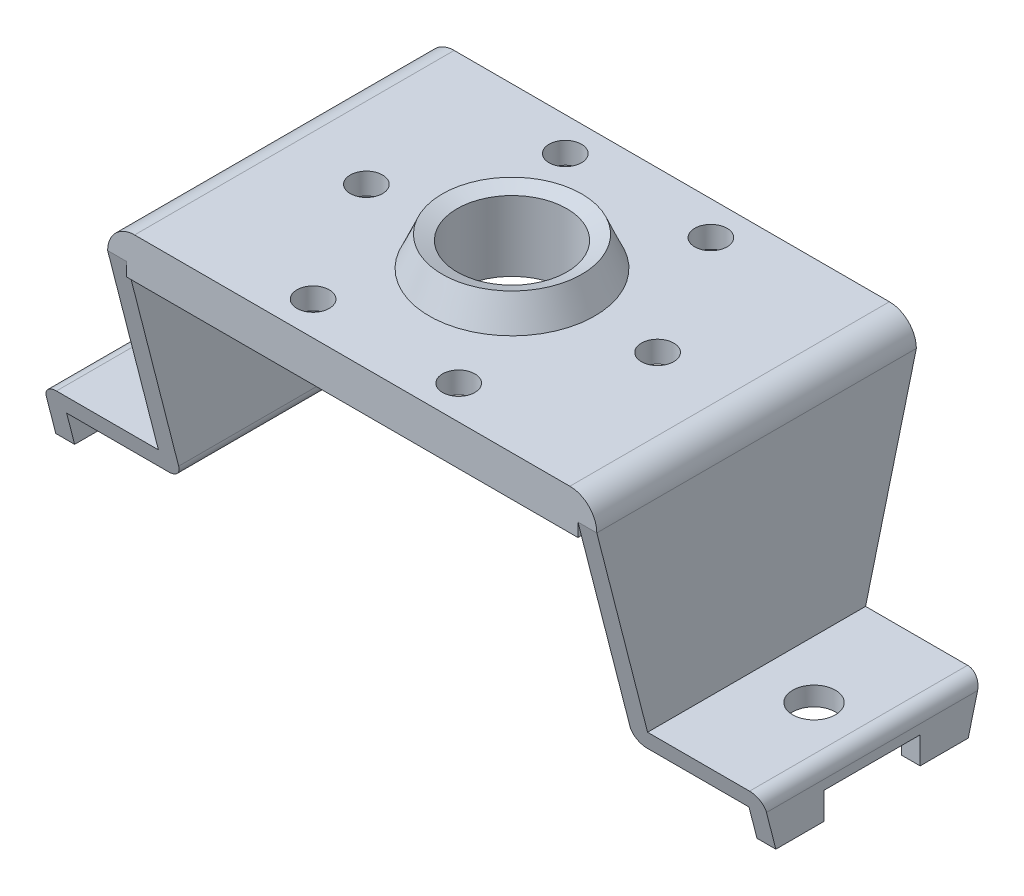
from build123d import *

# Parameters (mm, degrees)
SKETCH1_R                       = 7.7978
SKETCH1_R_2                     = 6.57225
SKETCH1_R_3                     = 5.17525
BOSS_EXTRUDE1_DEPTH             = 2.032
BOSS_EXTRUDE2_REACH             = 17.062
BOSS_EXTRUDE2_DIRECTION_2_REACH = 17.062
SKETCH4_W                       = 3.302
SKETCH4_H                       = 2.032
BOSS_EXTRUDE3_DEPTH             = 30.1244
FILLET1_R                       = 2.54
FILLET2_R                       = 2.54
SKETCH5_W                       = 9.0678
SKETCH5_H                       = 2.54
CUT_EXTRUDE1_DEPTH              = 116.84
SKETCH6_R                       = 2.01295
CUT_EXTRUDE2_DEPTH              = 5.7117
SKETCH7_R                       = 1.524
CUT_EXTRUDE3_DEPTH              = 26.9207
CUT_EXTRUDE4_DEPTH              = 116.84
CUT_EXTRUDE4_DEPTH_BACK         = 116.84
SKETCH9_W                       = 42.5577
SKETCH9_H                       = 30.1244
SKETCH9_W_2                     = 39.0017
SKETCH9_H_2                     = 26.5684
BOSS_EXTRUDE4_DEPTH             = 1.778


with BuildPart() as part:
    # Sketch1 → Boss-Extrude1 (new body)
    with BuildSketch(Plane(origin=(0, 0, 0), x_dir=(1, 0, 0), z_dir=(0, 1, 0))):
        with BuildLine():
            ThreePointArc((-23.05685, 9.9822), (-21.568952448, 13.574302448), (-17.97685, 15.0622))
            Line((-17.97685, 15.0622), (17.97685, 15.0622))
            ThreePointArc((17.97685, 15.0622), (21.568952448, 13.574302448), (23.05685, 9.9822))
            Line((23.05685, 9.9822), (23.05685, -9.9822))
            ThreePointArc((23.05685, -9.9822), (21.568952448, -13.574302448), (17.97685, -15.0622))
            Line((17.97685, -15.0622), (-17.97685, -15.0622))
            ThreePointArc((-17.97685, -15.0622), (-21.568952448, -13.574302448), (-23.05685, -9.9822))
            Line((-23.05685, -9.9822), (-23.05685, 9.9822))
        make_face()
        Circle(SKETCH1_R, mode=Mode.SUBTRACT)
        Circle(SKETCH1_R)
        Circle(SKETCH1_R_2, mode=Mode.SUBTRACT)
        Circle(SKETCH1_R_2)
        Circle(SKETCH1_R_3, mode=Mode.SUBTRACT)
    extrude(amount=-BOSS_EXTRUDE1_DEPTH)

    # Sketch2 → Revolve1 (revolve)
    with BuildSketch(Plane(origin=(0, 0, 0), x_dir=(0, 0, -1), z_dir=(1, 0, 0))):
        Polygon((-5.17525, 2.286), (-6.57225, 2.794), (-7.7978, 0), (-5.17525, 0), align=None)
    revolve1 = revolve(axis=Axis((0, 0, 0), (0, 1, 0)))

    # Boss-Extrude2: up to this face of the body (flat: up to its plane)
    boss_extrude2_end = Plane(part.part.faces().sort_by_distance((0, -1.016, 15.0622))[0])
    # Sketch3 → Boss-Extrude2 (add, up to the picked face)
    with BuildSketch(Plane.XY, mode=Mode.PRIVATE) as boss_extrude2_sk1:
        with BuildLine():
            ThreePointArc((-23.05685, -1.27), (-22.684875612, -0.371974388), (-21.78685, 0))
            Line((-21.78685, 0), (-21.27885, 0))
            Line((-21.27885, 0), (-21.27885, -21.717))
            ThreePointArc((-21.27885, -21.717), (-21.650824388, -22.615025612), (-22.54885, -22.987))
            Line((-22.54885, -22.987), (-23.05685, -22.987))
            Line((-23.05685, -22.987), (-32.16275, -22.987))
            Line((-32.16275, -22.987), (-32.16275, -25.9207))
            Line((-32.16275, -25.9207), (-33.94075, -25.9207))
            Line((-33.94075, -25.9207), (-33.94075, -22.479))
            ThreePointArc((-33.94075, -22.479), (-33.568775612, -21.580974388), (-32.67075, -21.209))
            Line((-32.67075, -21.209), (-32.16275, -21.209))
            Line((-32.16275, -21.209), (-23.05685, -21.209))
            Line((-23.05685, -21.209), (-23.05685, -1.27))
        make_face()
    boss_extrude2_tool1 = split(extrude(boss_extrude2_sk1.sketch, amount=BOSS_EXTRUDE2_REACH, mode=Mode.PRIVATE), bisect_by=boss_extrude2_end, keep=Keep.BOTH, mode=Mode.PRIVATE)
    add(boss_extrude2_tool1.solids().sort_by_distance((-32.41675, -21.49748, 0))[0])
    # Sketch3 → Boss-Extrude2 (add, up to the picked face)
    with BuildSketch(Plane.XY, mode=Mode.PRIVATE) as boss_extrude2_sk2:
        with BuildLine():
            Line((21.27885, 0), (21.27885, -21.717))
            ThreePointArc((21.27885, -21.717), (21.650824388, -22.615025612), (22.54885, -22.987))
            Line((22.54885, -22.987), (23.05685, -22.987))
            Line((23.05685, -22.987), (32.16275, -22.987))
            Line((32.16275, -22.987), (32.16275, -25.9207))
            Line((32.16275, -25.9207), (33.94075, -25.9207))
            Line((33.94075, -25.9207), (33.94075, -22.479))
            ThreePointArc((33.94075, -22.479), (33.568775612, -21.580974388), (32.67075, -21.209))
            Line((32.67075, -21.209), (32.16275, -21.209))
            Line((32.16275, -21.209), (23.05685, -21.209))
            Line((23.05685, -21.209), (23.05685, -1.27))
            ThreePointArc((23.05685, -1.27), (22.684875612, -0.371974388), (21.78685, 0))
            Line((21.78685, 0), (21.27885, 0))
        make_face()
    boss_extrude2_tool2 = split(extrude(boss_extrude2_sk2.sketch, amount=BOSS_EXTRUDE2_REACH, mode=Mode.PRIVATE), bisect_by=boss_extrude2_end, keep=Keep.BOTH, mode=Mode.PRIVATE)
    add(boss_extrude2_tool2.solids().sort_by_distance((32.41675, -21.49748, 0))[0])

    # Boss-Extrude2 direction 2: up to this face of the body (flat: up to its plane)
    boss_extrude2_direction_2_end = Plane(part.part.faces().sort_by_distance((0, -1.016, -15.0622))[0])
    # Sketch3 → Boss-Extrude2 direction 2 (add, up to the picked face)
    with BuildSketch(Plane.XY, mode=Mode.PRIVATE) as boss_extrude2_direction_2_sk1:
        with BuildLine():
            ThreePointArc((-23.05685, -1.27), (-22.684875612, -0.371974388), (-21.78685, 0))
            Line((-21.78685, 0), (-21.27885, 0))
            Line((-21.27885, 0), (-21.27885, -21.717))
            ThreePointArc((-21.27885, -21.717), (-21.650824388, -22.615025612), (-22.54885, -22.987))
            Line((-22.54885, -22.987), (-23.05685, -22.987))
            Line((-23.05685, -22.987), (-32.16275, -22.987))
            Line((-32.16275, -22.987), (-32.16275, -25.9207))
            Line((-32.16275, -25.9207), (-33.94075, -25.9207))
            Line((-33.94075, -25.9207), (-33.94075, -22.479))
            ThreePointArc((-33.94075, -22.479), (-33.568775612, -21.580974388), (-32.67075, -21.209))
            Line((-32.67075, -21.209), (-32.16275, -21.209))
            Line((-32.16275, -21.209), (-23.05685, -21.209))
            Line((-23.05685, -21.209), (-23.05685, -1.27))
        make_face()
    boss_extrude2_direction_2_tool1 = split(extrude(boss_extrude2_direction_2_sk1.sketch, amount=-BOSS_EXTRUDE2_DIRECTION_2_REACH, mode=Mode.PRIVATE), bisect_by=boss_extrude2_direction_2_end, keep=Keep.BOTH, mode=Mode.PRIVATE)
    add(boss_extrude2_direction_2_tool1.solids().sort_by_distance((-32.41675, -21.49748, 0))[0])
    # Sketch3 → Boss-Extrude2 direction 2 (add, up to the picked face)
    with BuildSketch(Plane.XY, mode=Mode.PRIVATE) as boss_extrude2_direction_2_sk2:
        with BuildLine():
            Line((21.27885, 0), (21.27885, -21.717))
            ThreePointArc((21.27885, -21.717), (21.650824388, -22.615025612), (22.54885, -22.987))
            Line((22.54885, -22.987), (23.05685, -22.987))
            Line((23.05685, -22.987), (32.16275, -22.987))
            Line((32.16275, -22.987), (32.16275, -25.9207))
            Line((32.16275, -25.9207), (33.94075, -25.9207))
            Line((33.94075, -25.9207), (33.94075, -22.479))
            ThreePointArc((33.94075, -22.479), (33.568775612, -21.580974388), (32.67075, -21.209))
            Line((32.67075, -21.209), (32.16275, -21.209))
            Line((32.16275, -21.209), (23.05685, -21.209))
            Line((23.05685, -21.209), (23.05685, -1.27))
            ThreePointArc((23.05685, -1.27), (22.684875612, -0.371974388), (21.78685, 0))
            Line((21.78685, 0), (21.27885, 0))
        make_face()
    boss_extrude2_direction_2_tool2 = split(extrude(boss_extrude2_direction_2_sk2.sketch, amount=-BOSS_EXTRUDE2_DIRECTION_2_REACH, mode=Mode.PRIVATE), bisect_by=boss_extrude2_direction_2_end, keep=Keep.BOTH, mode=Mode.PRIVATE)
    add(boss_extrude2_direction_2_tool2.solids().sort_by_distance((32.41675, -21.49748, 0))[0])

    # Sketch4 → Boss-Extrude3 (add)
    with BuildSketch(Plane.XY.offset(15.0622)):
        with BuildLine():
            ThreePointArc((-23.05685, -1.27), (-22.684875612, -0.371974388), (-21.78685, 0))
            Line((-21.78685, 0), (-23.05685, 0))
            Line((-23.05685, 0), (-23.05685, -1.27))
        make_face()
        with BuildLine():
            Line((-21.27885, -2.032), (-21.27885, 0))
            Line((-21.27885, 0), (-21.78685, 0))
            ThreePointArc((-21.78685, 0), (-22.684875612, -0.371974388), (-23.05685, -1.27))
            Line((-23.05685, -1.27), (-23.05685, -2.032))
            Line((-23.05685, -2.032), (-21.27885, -2.032))
        make_face()
        with Locations((-19.62785, -1.016)):
            Rectangle(SKETCH4_W, SKETCH4_H)
        Polygon((23.05685, 0), (21.27885, 0), (17.97685, 0), (17.97685, -2.032), (21.27885, -2.032), (23.05685, -2.032), align=None)
    extrude(amount=-BOSS_EXTRUDE3_DEPTH)

    # Fillet1
    fillet1_edges = [part.edges().sort_by_distance(p)[0] for p in [
        (23.05685, 0, 0),
    ]]
    fillet(fillet1_edges, radius=FILLET1_R)

    # Fillet2
    fillet2_edges = [part.edges().sort_by_distance(p)[0] for p in [
        (-23.05685, 0, 0),
    ]]
    fillet(fillet2_edges, radius=FILLET2_R)

    # Sketch5 → Cut-Extrude1 (cut)
    with BuildSketch(Plane.ZY.offset(33.94075)):
        with Locations((0, -24.6507)):
            Rectangle(SKETCH5_W, SKETCH5_H)
    extrude(amount=-CUT_EXTRUDE1_DEPTH, mode=Mode.SUBTRACT)

    # Sketch6 → Cut-Extrude2 (cut, through all)
    with BuildSketch(Plane(origin=(0, -21.209, 0), x_dir=(1, 0, 0), z_dir=(0, 1, 0))):
        with Locations((-28.4734, 0)):
            Circle(SKETCH6_R)
        with Locations((28.4734, 0)):
            Circle(SKETCH6_R)
    extrude(amount=-CUT_EXTRUDE2_DEPTH, mode=Mode.SUBTRACT)

    # Sketch7 → Cut-Extrude3 (cut, through all)
    with BuildSketch(Plane(origin=(0, 0, 0), x_dir=(1, 0, 0), z_dir=(0, 1, 0))):
        with Locations((13.725830849, 0)):
            Circle(SKETCH7_R)
        with Locations((-13.725830849, 0)):
            Circle(SKETCH7_R)
        with Locations((-6.862915424, -11.886918203)):
            Circle(SKETCH7_R)
        with Locations((6.862915424, 11.886918203)):
            Circle(SKETCH7_R)
        with Locations((-6.862915424, 11.886918203)):
            Circle(SKETCH7_R)
        with Locations((6.862915424, -11.886918203)):
            Circle(SKETCH7_R)
    extrude(amount=-CUT_EXTRUDE3_DEPTH, mode=Mode.SUBTRACT)

    # Sketch8 → Cut-Extrude4 (cut, two sides)
    with BuildSketch(Plane.ZY.offset(23.05685)) as cut_extrude4_sk:
        Polygon((-15.0622, -2.54), (-9.0678, -25.9207), (-15.0622, -25.9207), align=None)
        Polygon((9.0678, -25.9207), (15.0622, -2.54), (15.0622, -25.9207), align=None)
    extrude(amount=CUT_EXTRUDE4_DEPTH, mode=Mode.SUBTRACT)
    extrude(cut_extrude4_sk.sketch, amount=-CUT_EXTRUDE4_DEPTH_BACK, mode=Mode.SUBTRACT)

    # Mirror4: Revolve1 across plane
    add(revolve1.mirror(Plane.ZX.offset(-1.016)))

    # Sketch9 → Boss-Extrude4 (add)
    with BuildSketch(Plane.XZ.offset(2.032)):
        Rectangle(SKETCH9_W, SKETCH9_H)
        Rectangle(SKETCH9_W_2, SKETCH9_H_2, mode=Mode.SUBTRACT)
    extrude(amount=BOSS_EXTRUDE4_DEPTH)


solid = part.part
